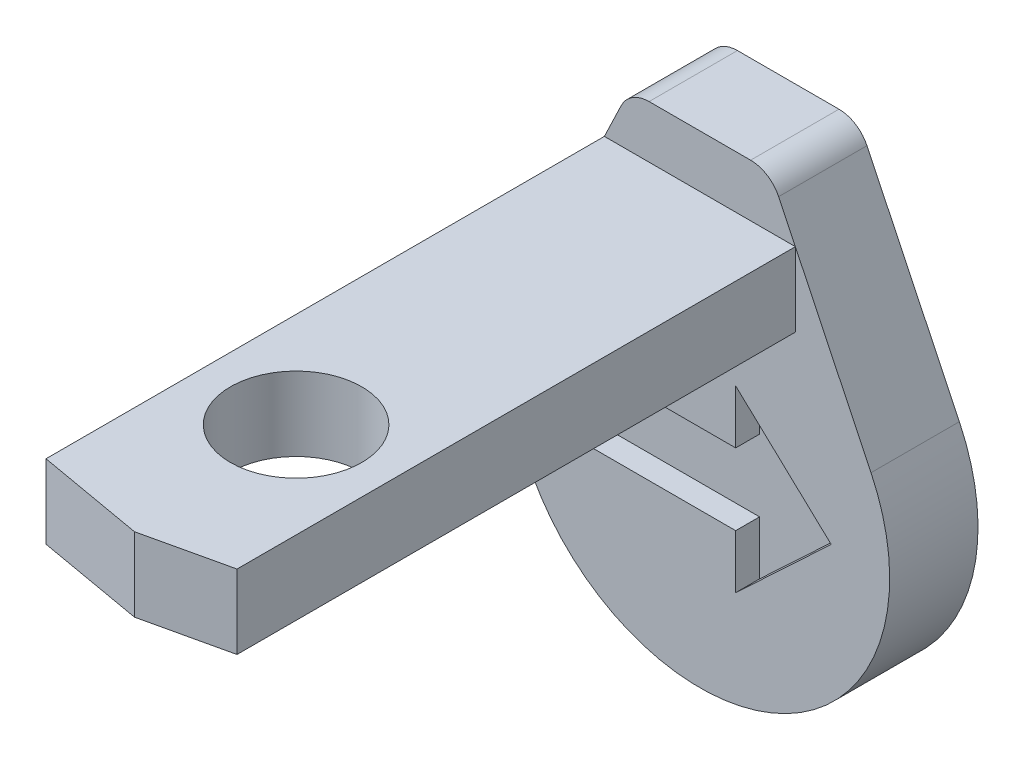
from build123d import *

# Parameters (mm, degrees)
SKETCH1_R           = 79.5
BOSS_EXTRUDE1_DEPTH = 37
SKETCH2_W           = 80
SKETCH2_H           = 31
BOSS_EXTRUDE2_DEPTH = 212.65
BOSS_EXTRUDE3_DEPTH = 31
CUT_EXTRUDE1_DEPTH  = 10
SKETCH5_R           = 27.5
CUT_EXTRUDE2_DEPTH  = 181


with BuildPart() as part:
    # Sketch1 → Boss-Extrude1 (new body)
    with BuildSketch(Plane.XY):
        with BuildLine():
            ThreePointArc((-21.261874522, 100), (-28.188531545, 98.000973706), (-32.984947104, 92.618680381))
            Line((-32.984947104, 92.618680381), (-71.691097716, 11.860391562))
            ThreePointArc((-71.691097716, 11.860391562), (0, 57), (71.691097716, 11.860391562))
            Line((71.691097716, 11.860391562), (32.984947104, 92.618680381))
            ThreePointArc((32.984947104, 92.618680381), (28.188531545, 98.000973706), (21.261874522, 100))
            Line((21.261874522, 100), (-21.261874522, 100))
        make_face()
        with Locations((0, -22.5)):
            Circle(SKETCH1_R)
    extrude(amount=BOSS_EXTRUDE1_DEPTH)

    # Sketch2 → Boss-Extrude2 (add)
    with BuildSketch(Plane.XY.offset(37)):
        with Locations((0, 62.5)):
            Rectangle(SKETCH2_W, SKETCH2_H)
    extrude(amount=BOSS_EXTRUDE2_DEPTH)

    # Sketch3 → Boss-Extrude3 (add)
    with BuildSketch(Plane(origin=(0, 78, 0), x_dir=(1, 0, 0), z_dir=(0, 1, 0))):
        Polygon((5, -278.784714132), (40, -270.85), (40, -249.65), (-40, -249.65), (-40, -270.85), align=None)
    extrude(amount=-BOSS_EXTRUDE3_DEPTH)

    # Sketch4 → Cut-Extrude1 (cut)
    with BuildSketch(Plane.XY.offset(37)):
        Polygon((55, -22.5), (15, 15), (15, -7.5), (-50, -7.5), (-50, -37.5), (15, -37.5), (15, -60), align=None)
    extrude(amount=-CUT_EXTRUDE1_DEPTH, mode=Mode.SUBTRACT)

    # Sketch5 → Cut-Extrude2 (cut, through all)
    with BuildSketch(Plane(origin=(0, 78, 0), x_dir=(1, 0, 0), z_dir=(0, 1, 0))):
        with Locations((0, -206.1)):
            Circle(SKETCH5_R)
    extrude(amount=-CUT_EXTRUDE2_DEPTH, mode=Mode.SUBTRACT)


solid = part.part
